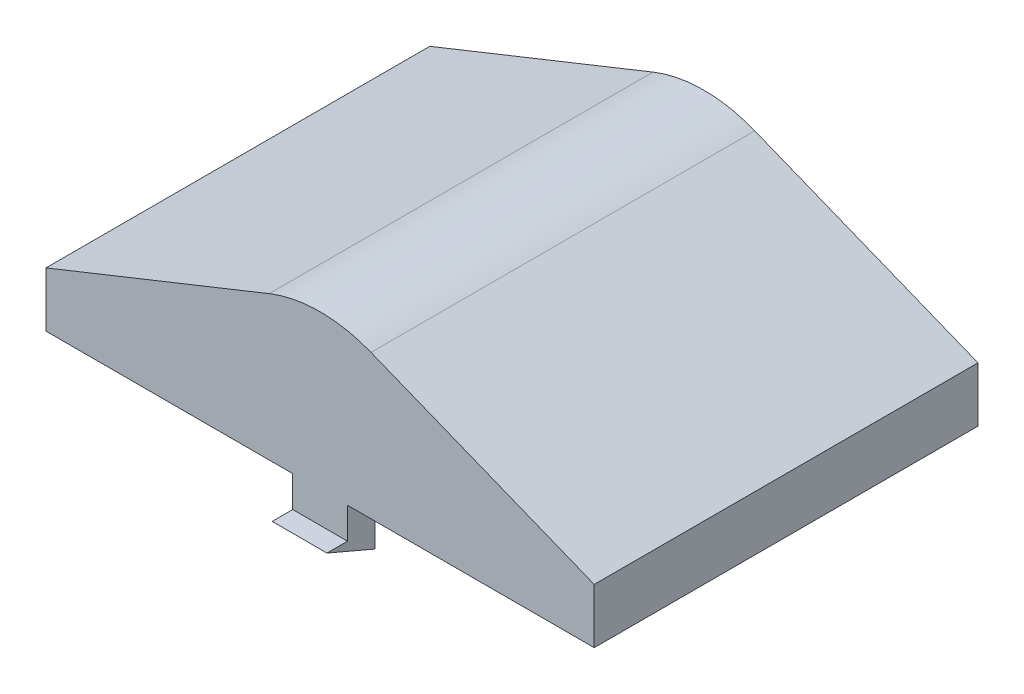
from build123d import *

# Parameters (mm, degrees)
EXTRUDE1_DEPTH = 7
FILLET1_R      = 5
SHELL1_T       = -1
EXTRUDE2_DEPTH = 1


with BuildPart() as part:
    # Sketch1 → Extrude1 (new body, symmetric)
    with BuildSketch(Plane.XY):
        Polygon((-10, 0), (10, 0), (10, 2), (0, 6), (-10, 2), align=None)
    extrude(amount=EXTRUDE1_DEPTH, both=True)

    # Fillet1
    fillet1_edges = [part.edges().sort_by_distance(p)[0] for p in [
        (0, 6, 0),
    ]]
    fillet(fillet1_edges, radius=FILLET1_R)

    # Shell1
    shell1_openings = [part.faces().sort_by_distance(p)[0] for p in [
        (0, 0, 0),
    ]]
    offset(amount=SHELL1_T, openings=shell1_openings, kind=Kind.INTERSECTION)

    # Sketch2 → Extrude2 (add, symmetric)
    with BuildSketch(Plane(origin=(0, 0, 0), x_dir=(0, 0, -1), z_dir=(1, 0, 0))):
        Polygon((-6, 0), (-7, 0), (-7, -1.135164807), (-7.75, -1.135164807), (-6, -1.885164807), align=None)
    extrude2 = extrude(amount=EXTRUDE2_DEPTH, both=True)

    # Mirror1: Extrude2 across plane
    add(extrude2.mirror(Plane.XY))


solid = part.part
